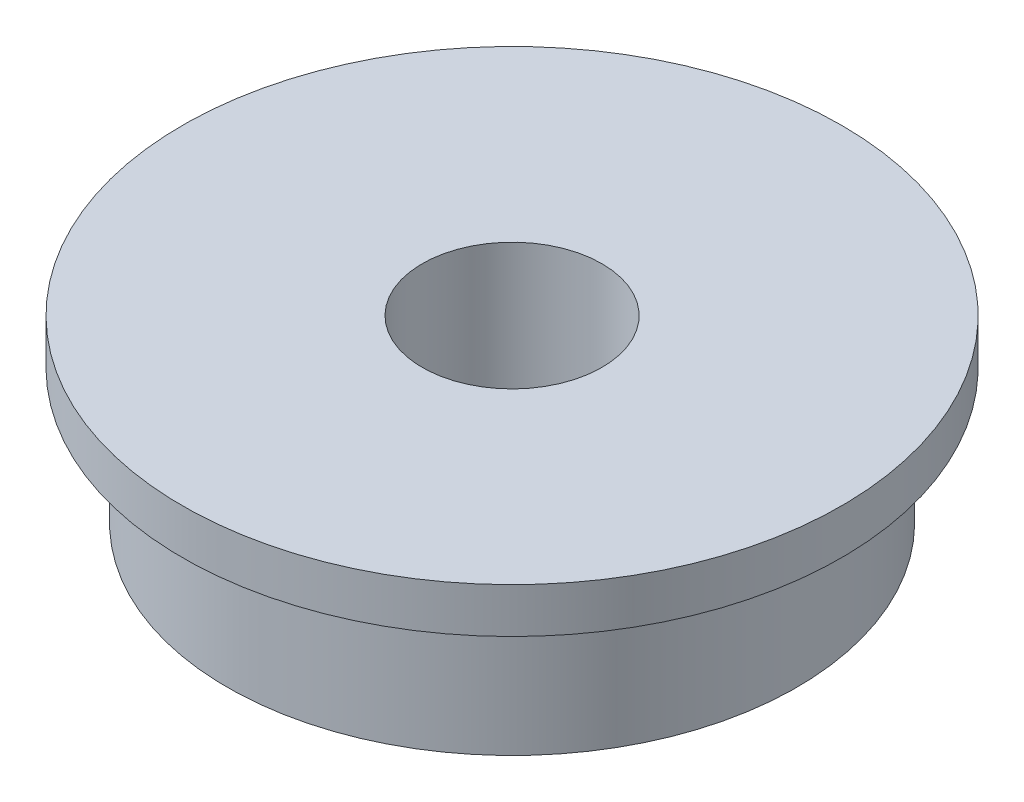
from build123d import *


with BuildPart() as part:
    # Sketch1 → Revolve1 (revolve)
    with BuildSketch(Plane.XY):
        Polygon((3, 6), (3, 0), (9.5, 0), (9.5, 4.5), (11, 4.5), (11, 6), align=None)
    revolve(axis=Axis((0, 0, 0), (0, 1, 0)))


solid = part.part
